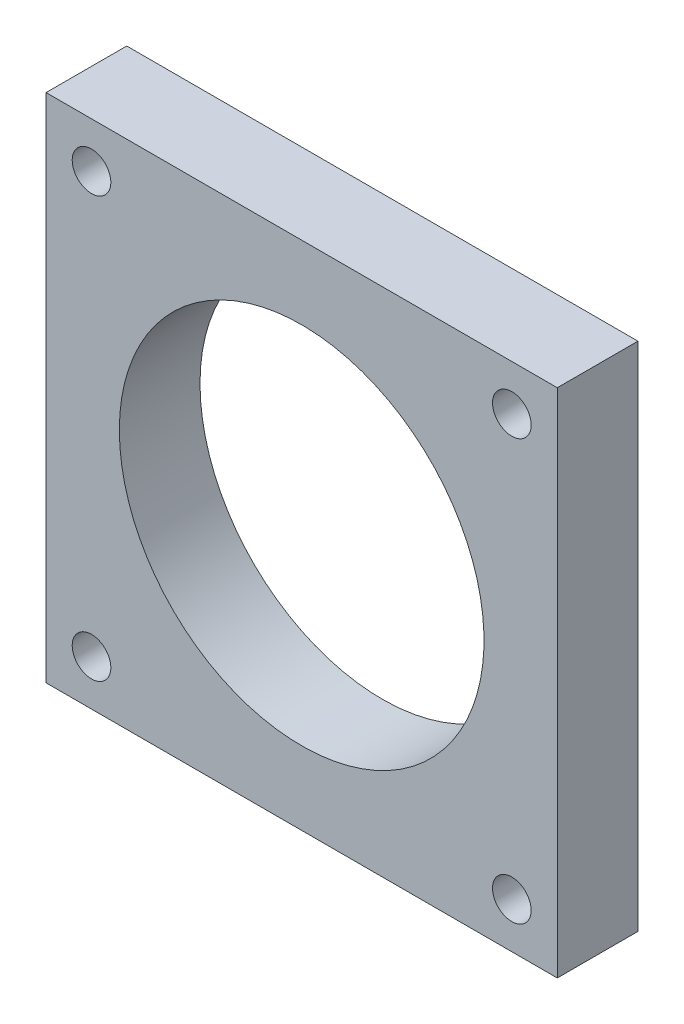
from build123d import *

# Parameters (mm, degrees)
SKETCH1_W                      = 45
SKETCH1_H                      = 45
SKETCH1_R                      = 16
BOSS_EXTRUDE1_DEPTH            = 7.1
M3X0_5_TAPPED_HOLE1_D          = 2.5
M3X0_5_TAPPED_HOLE1_DEPTH      = 15
M3X0_5_TAPPED_HOLE1_TIP        = 0.751075774
CBORE_FOR_M3_SHCS1_D           = 3.4
CBORE_FOR_M3_SHCS1_DEPTH       = 7.1
CBORE_FOR_M3_SHCS1_CBORE_D     = 6.5
CBORE_FOR_M3_SHCS1_CBORE_DEPTH = 3
CBORE_FOR_M3_SHCS1_TIP         = 1.021463052
F_3D_PRINTING_TOLERANCE_BY     = 0.05


with BuildPart() as part:
    # Sketch1 → Boss-Extrude1 (new body)
    with BuildSketch(Plane.XY):
        Rectangle(SKETCH1_W, SKETCH1_H)
        Circle(SKETCH1_R, mode=Mode.SUBTRACT)
    extrude(amount=BOSS_EXTRUDE1_DEPTH)

    # M3x0.5 Tapped Hole1
    with Locations(Plane(origin=(0, 0, 0), x_dir=(-1, 0, 0), z_dir=(0, 0, -1))):
        with Locations((-18.5, 18.5), (-18.5, -18.5), (18.5, -18.5), (18.5, 18.5)):
            Hole(M3X0_5_TAPPED_HOLE1_D / 2, depth=M3X0_5_TAPPED_HOLE1_DEPTH)
            with Locations((0, 0, -(M3X0_5_TAPPED_HOLE1_DEPTH + M3X0_5_TAPPED_HOLE1_TIP / 2))):  # 118° drill point
                Cone(0, M3X0_5_TAPPED_HOLE1_D / 2, M3X0_5_TAPPED_HOLE1_TIP, mode=Mode.SUBTRACT)

    # CBORE for M3 SHCS1
    with Locations(Plane(origin=(0, 0, 0), x_dir=(-1, 0, 0), z_dir=(0, 0, -1))):
        with Locations((-18.5, 18.5), (18.5, 18.5), (18.5, -18.5), (-18.5, -18.5)):
            CounterBoreHole(CBORE_FOR_M3_SHCS1_D / 2, CBORE_FOR_M3_SHCS1_CBORE_D / 2, CBORE_FOR_M3_SHCS1_CBORE_DEPTH, depth=CBORE_FOR_M3_SHCS1_DEPTH)
            with Locations((0, 0, -(CBORE_FOR_M3_SHCS1_DEPTH + CBORE_FOR_M3_SHCS1_TIP / 2))):  # 118° drill point
                Cone(0, CBORE_FOR_M3_SHCS1_D / 2, CBORE_FOR_M3_SHCS1_TIP, mode=Mode.SUBTRACT)

    # 3D Printing Tolerance: a curved face moved inward by 0.05
    add(Solid.thicken(part.faces().sort_by_distance((-16, 0, 3.55))[0], -F_3D_PRINTING_TOLERANCE_BY), mode=Mode.SUBTRACT)


solid = part.part
